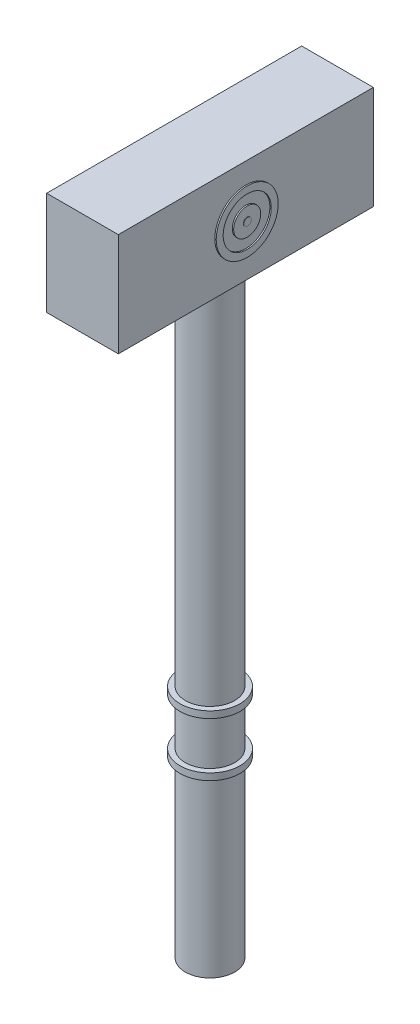
from build123d import *

# Parameters (mm, degrees)
SKETCH2_R            = 36.75
SKETCH2_R_2          = 31.75
BOSS_EXTRUDE2_DEPTH  = 900
BOSS_EXTRUDE10_DEPTH = 5
CIRPATTERN3_COUNT    = 4
BOSS_EXTRUDE11_START = -10
SKETCH5_R            = 44.75
SKETCH5_R_2          = 36.75
BOSS_EXTRUDE11_DEPTH = 10
LPATTERN1_COUNT      = 2
LPATTERN1_PITCH      = 80
BOSS_EXTRUDE12_DEPTH = 53.34
SKETCH7_R            = 46.138276775
SKETCH7_R_2          = 35.802049151
BOSS_EXTRUDE15_DEPTH = 55.372
SKETCH8_R            = 20.14340108
BOSS_EXTRUDE16_DEPTH = 55.372
SKETCH9_R            = 5.663284778
BOSS_EXTRUDE18_DEPTH = 55.88
SCALE1_SCALE         = 0.1


with BuildPart() as part:
    # Sketch2 → Boss-Extrude2 (new body)
    with BuildSketch(Plane(origin=(0, 10, 0), x_dir=(1, 0, 0), z_dir=(0, 1, 0))):
        Circle(SKETCH2_R)
        Circle(SKETCH2_R_2, mode=Mode.SUBTRACT)
    extrude(amount=BOSS_EXTRUDE2_DEPTH)

    # Sketch5 → Boss-Extrude11 (add)
    with BuildSketch(Plane(origin=(0, 280.000000004, 0), x_dir=(1, 0, 0), z_dir=(0, 1, 0)).offset(BOSS_EXTRUDE11_START)):
        Circle(SKETCH5_R)
        Circle(SKETCH5_R_2, mode=Mode.SUBTRACT)
    boss_extrude11 = extrude(amount=BOSS_EXTRUDE11_DEPTH)

    # LPattern1: Boss-Extrude11 ×2
    with Locations(*[(0, i * LPATTERN1_PITCH, 0) for i in range(1, LPATTERN1_COUNT)]):
        add(boss_extrude11)

    # Sketch6 → Boss-Extrude12 (add, symmetric)
    with BuildSketch(Plane(origin=(0, 0, 0), x_dir=(0, 0, -1), z_dir=(1, 0, 0))):
        Polygon((-36.75, 910), (-189.768574018, 910), (-189.768574018, 1063.746484801), (189.768574018, 1063.746484801), (189.768574018, 910), (36.75, 910), align=None)
    extrude(amount=BOSS_EXTRUDE12_DEPTH, both=True)

    # Sketch7 → Boss-Extrude15 (add)
    with BuildSketch(Plane(origin=(0, 0, 0), x_dir=(0, 0, -1), z_dir=(1, 0, 0))):
        with Locations((0, 986.650763521)):
            Circle(SKETCH7_R)
        with Locations((0, 986.650763521)):
            Circle(SKETCH7_R_2, mode=Mode.SUBTRACT)
    extrude(amount=BOSS_EXTRUDE15_DEPTH)

    # Sketch8 → Boss-Extrude16 (add)
    with BuildSketch(Plane(origin=(0, 0, 0), x_dir=(0, 0, -1), z_dir=(1, 0, 0))):
        with Locations((0, 986.650763521)):
            Circle(SKETCH8_R)
    extrude(amount=BOSS_EXTRUDE16_DEPTH)

    # Sketch9 → Boss-Extrude18 (add)
    with BuildSketch(Plane(origin=(0, 0, 0), x_dir=(0, 0, -1), z_dir=(1, 0, 0))):
        with Locations((0, 986.650763521)):
            Circle(SKETCH9_R)
    extrude(amount=BOSS_EXTRUDE18_DEPTH)


with BuildPart() as body_2:
    # Sketch4 → Boss-Extrude10 (new, symmetric)
    with BuildSketch(Plane.XY):
        Polygon((-125, 10), (-125, 37.123747586), (-87.807861708, 71.973477342), (-36.75, 71.973477342), (-36.75, 10), align=None)
    extrude(amount=BOSS_EXTRUDE10_DEPTH, both=True)


with BuildPart() as cirpattern3_1:
    # CirPattern3: pattern copy
    add(body_2.part.rotate(Axis((0, 0, 0), (0, -1, 0)), 1 * 360 / CIRPATTERN3_COUNT))


with BuildPart() as cirpattern3_2:
    # CirPattern3: pattern copy
    add(body_2.part.rotate(Axis((0, 0, 0), (0, -1, 0)), 2 * 360 / CIRPATTERN3_COUNT))


with BuildPart() as cirpattern3_3:
    # CirPattern3: pattern copy
    add(body_2.part.rotate(Axis((0, 0, 0), (0, -1, 0)), 3 * 360 / CIRPATTERN3_COUNT))


with BuildPart() as part_1:
    # Scale1: scaled about (0, 0, 0)
    add(part.part.scale(SCALE1_SCALE))


solid = part_1.part
